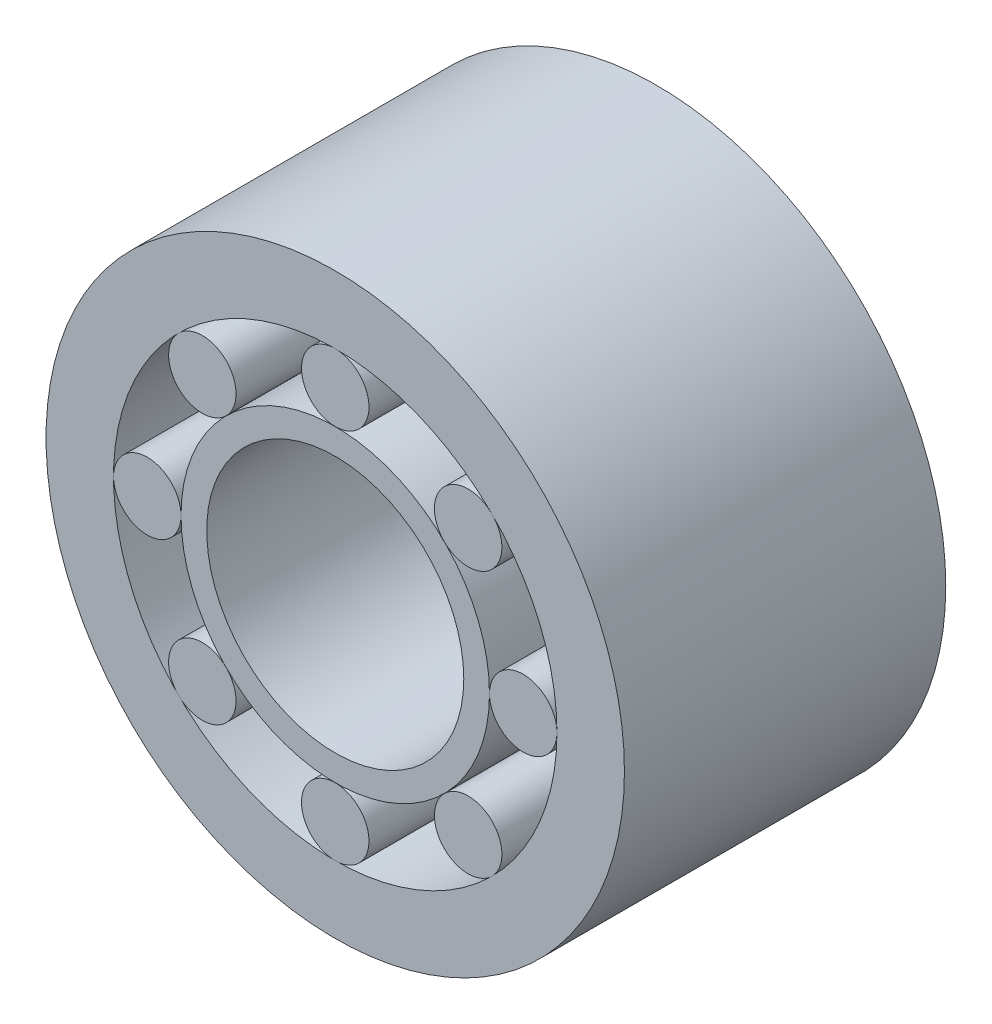
from build123d import *

# Parameters (mm, degrees)
SKETCH_1_R               = 90
SKETCH_1_R_2             = 40
EXTRUDE_1_DEPTH          = 100
SKETCH_2_R               = 69
SKETCH_2_R_2             = 48
CUT_EXTRUDE_2_DEPTH      = 101
SKETCH_3_W               = 30
SKETCH_3_H               = 10.5
SKETCH_3_W_2             = 29.947115327
PATTERN_CIRCULAR_4_COUNT = 8
SKETCH_4_W               = 5
SKETCH_4_H               = 5
SKETCH_4_W_2             = 5.048558916


with BuildPart() as part:
    # 草图1 → 凸台-拉伸1 (new body)
    with BuildSketch(Plane.XY):
        Circle(SKETCH_1_R)
        Circle(SKETCH_1_R_2, mode=Mode.SUBTRACT)
    extrude(amount=EXTRUDE_1_DEPTH)

    # 草图2 → 切除-拉伸2 (cut, through all)
    with BuildSketch(Plane.XY):
        Circle(SKETCH_2_R)
        Circle(SKETCH_2_R_2, mode=Mode.SUBTRACT)
    extrude(amount=CUT_EXTRUDE_2_DEPTH, mode=Mode.SUBTRACT)


with BuildPart() as body_2:
    # 草图3 → 旋转1 (revolve)
    with BuildSketch(Plane(origin=(0, 0, 0), x_dir=(0, 0, -1), z_dir=(1, 0, 0))):
        with Locations((-85, 63.75)):
            Rectangle(SKETCH_3_W, SKETCH_3_H)
        with Locations((-50.026442336, 63.75)):
            Rectangle(SKETCH_3_W_2, SKETCH_3_H)
        with Locations((-15.004325757, 63.75)):
            Rectangle(SKETCH_3_W, SKETCH_3_H)
    revolve(axis=Axis((0, 58.5, 100), (0, 0, -1)))


with BuildPart() as pattern_circular_4_1:
    # 阵列(圆周)4: pattern copy
    add(body_2.part.rotate(Axis((0, 0, 0), (0, 0, 1)), 1 * 360 / PATTERN_CIRCULAR_4_COUNT))


with BuildPart() as pattern_circular_4_2:
    # 阵列(圆周)4: pattern copy
    add(body_2.part.rotate(Axis((0, 0, 0), (0, 0, 1)), 2 * 360 / PATTERN_CIRCULAR_4_COUNT))


with BuildPart() as pattern_circular_4_3:
    # 阵列(圆周)4: pattern copy
    add(body_2.part.rotate(Axis((0, 0, 0), (0, 0, 1)), 3 * 360 / PATTERN_CIRCULAR_4_COUNT))


with BuildPart() as pattern_circular_4_4:
    # 阵列(圆周)4: pattern copy
    add(body_2.part.rotate(Axis((0, 0, 0), (0, 0, 1)), 4 * 360 / PATTERN_CIRCULAR_4_COUNT))


with BuildPart() as pattern_circular_4_5:
    # 阵列(圆周)4: pattern copy
    add(body_2.part.rotate(Axis((0, 0, 0), (0, 0, 1)), 5 * 360 / PATTERN_CIRCULAR_4_COUNT))


with BuildPart() as pattern_circular_4_6:
    # 阵列(圆周)4: pattern copy
    add(body_2.part.rotate(Axis((0, 0, 0), (0, 0, 1)), 6 * 360 / PATTERN_CIRCULAR_4_COUNT))


with BuildPart() as pattern_circular_4_7:
    # 阵列(圆周)4: pattern copy
    add(body_2.part.rotate(Axis((0, 0, 0), (0, 0, 1)), 7 * 360 / PATTERN_CIRCULAR_4_COUNT))


with BuildPart() as body_10:
    # 草图4 → 旋转4 (revolve)
    with BuildSketch(Plane(origin=(0, 0, 0), x_dir=(0, 0, -1), z_dir=(1, 0, 0))):
        with Locations((-67.5, 50.5)):
            Rectangle(SKETCH_4_W, SKETCH_4_H)
        with Locations((-32.528605215, 50.5)):
            Rectangle(SKETCH_4_W_2, SKETCH_4_H)
    revolve(axis=Axis((0, 0, 111.269553472), (0, 0, -1)))


solid = Compound([part.part, body_2.part, pattern_circular_4_1.part, pattern_circular_4_2.part, pattern_circular_4_3.part, pattern_circular_4_4.part, pattern_circular_4_5.part, pattern_circular_4_6.part, pattern_circular_4_7.part, body_10.part])
